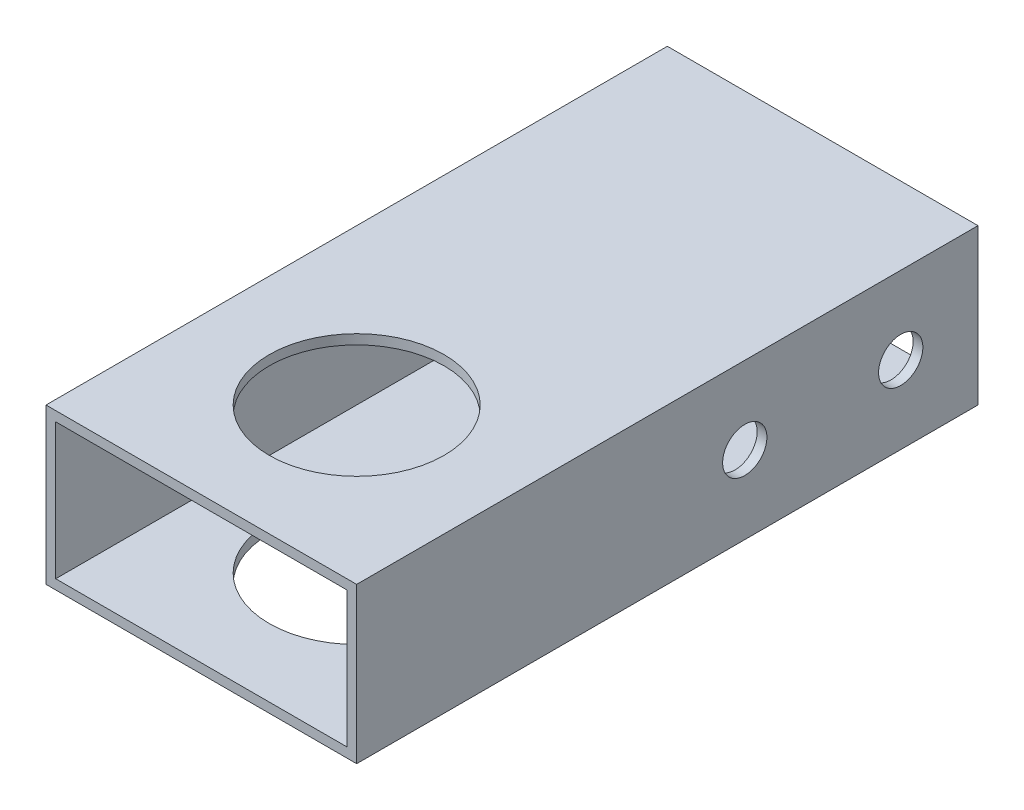
from build123d import *

# Parameters (mm, degrees)
SKETCH1_W               = 50.8
SKETCH1_H               = 25.4
SKETCH1_W_2             = 47.625
SKETCH1_H_2             = 22.225
BOSS_EXTRUDE1_DEPTH     = 101.6
SKETCH2_R               = 14.2875
CUT_EXTRUDE1_DEPTH      = 26.4
SKETCH3_R               = 3.6195
CUT_EXTRUDE2_DEPTH      = 1
CUT_EXTRUDE2_DEPTH_BACK = 51.8


with BuildPart() as part:
    # Sketch1 → Boss-Extrude1 (new body)
    with BuildSketch(Plane.XY):
        Rectangle(SKETCH1_W, SKETCH1_H)
        Rectangle(SKETCH1_W_2, SKETCH1_H_2, mode=Mode.SUBTRACT)
    extrude(amount=BOSS_EXTRUDE1_DEPTH)

    # Sketch2 → Cut-Extrude1 (cut, through all)
    with BuildSketch(Plane.XZ.offset(12.7)):
        with Locations((0, 76.2)):
            Circle(SKETCH2_R)
    extrude(amount=-CUT_EXTRUDE1_DEPTH, mode=Mode.SUBTRACT)

    # Sketch3 → Cut-Extrude2 (cut, two sides)
    with BuildSketch(Plane(origin=(25.4, 0, 0), x_dir=(0, 0, -1), z_dir=(1, 0, 0))) as cut_extrude2_sk:
        with Locations((-38.1381, 0)):
            Circle(SKETCH3_R)
        with Locations((-12.6365, 0)):
            Circle(SKETCH3_R)
    extrude(amount=CUT_EXTRUDE2_DEPTH, mode=Mode.SUBTRACT)
    extrude(cut_extrude2_sk.sketch, amount=-CUT_EXTRUDE2_DEPTH_BACK, mode=Mode.SUBTRACT)


solid = part.part
